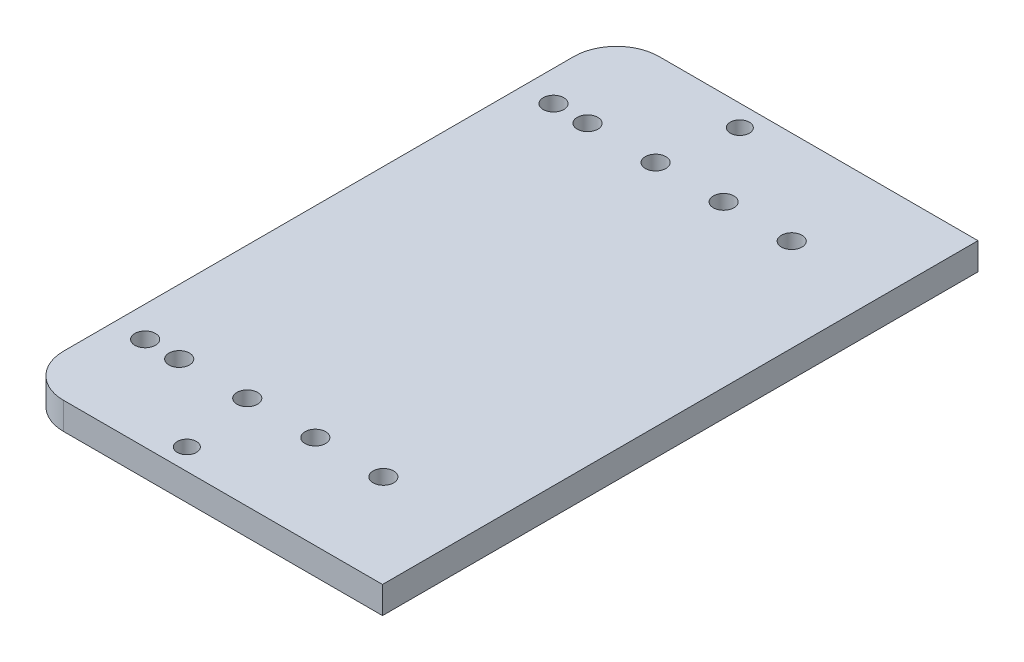
from build123d import *

# Parameters (mm, degrees)
SKETCH1_W           = 85
SKETCH1_H           = 140
BOSS_EXTRUDE1_DEPTH = 6.35
FILLET1_R           = 10
SKETCH2_R           = 2.425
CUT_EXTRUDE1_DEPTH  = 6.35
SKETCH3_R           = 2.25
CUT_EXTRUDE2_DEPTH  = 10


with BuildPart() as part:
    # Sketch1 → Boss-Extrude1 (new body)
    with BuildSketch(Plane(origin=(0, 0, 0), x_dir=(1, 0, 0), z_dir=(0, 1, 0))):
        with Locations((-160.106308554, -105.56948084)):
            Rectangle(SKETCH1_W, SKETCH1_H)
    extrude(amount=BOSS_EXTRUDE1_DEPTH)

    # Fillet1
    fillet1_edges = [part.edges().sort_by_distance(p)[0] for p in [
        (-202.606308554, 3.175, 35.56948084),
        (-202.606308554, 3.175, 175.56948084),
    ]]
    fillet(fillet1_edges, radius=FILLET1_R)

    # Sketch2 → Cut-Extrude1 (cut)
    with BuildSketch(Plane.XZ):
        with Locations((-139.406308554, 57.56948084)):
            Circle(SKETCH2_R)
        with Locations((-155.406308554, 57.56948084)):
            Circle(SKETCH2_R)
        with Locations((-171.406308554, 57.56948084)):
            Circle(SKETCH2_R)
        with Locations((-187.406308554, 57.56948084)):
            Circle(SKETCH2_R)
        with Locations((-195.406308554, 57.56948084)):
            Circle(SKETCH2_R)
        with Locations((-139.406308554, 153.56948084)):
            Circle(SKETCH2_R)
        with Locations((-155.406308554, 153.56948084)):
            Circle(SKETCH2_R)
        with Locations((-171.406308554, 153.56948084)):
            Circle(SKETCH2_R)
        with Locations((-187.406308554, 153.56948084)):
            Circle(SKETCH2_R)
        with Locations((-195.406308554, 153.56948084)):
            Circle(SKETCH2_R)
    extrude(amount=-CUT_EXTRUDE1_DEPTH, mode=Mode.SUBTRACT)

    # Sketch3 → Cut-Extrude2 (cut)
    with BuildSketch(Plane.XZ):
        with Locations((-168.606308554, 170.56948084)):
            Circle(SKETCH3_R)
        with Locations((-168.606308554, 40.56948084)):
            Circle(SKETCH3_R)
    extrude(amount=-CUT_EXTRUDE2_DEPTH, mode=Mode.SUBTRACT)


solid = part.part
